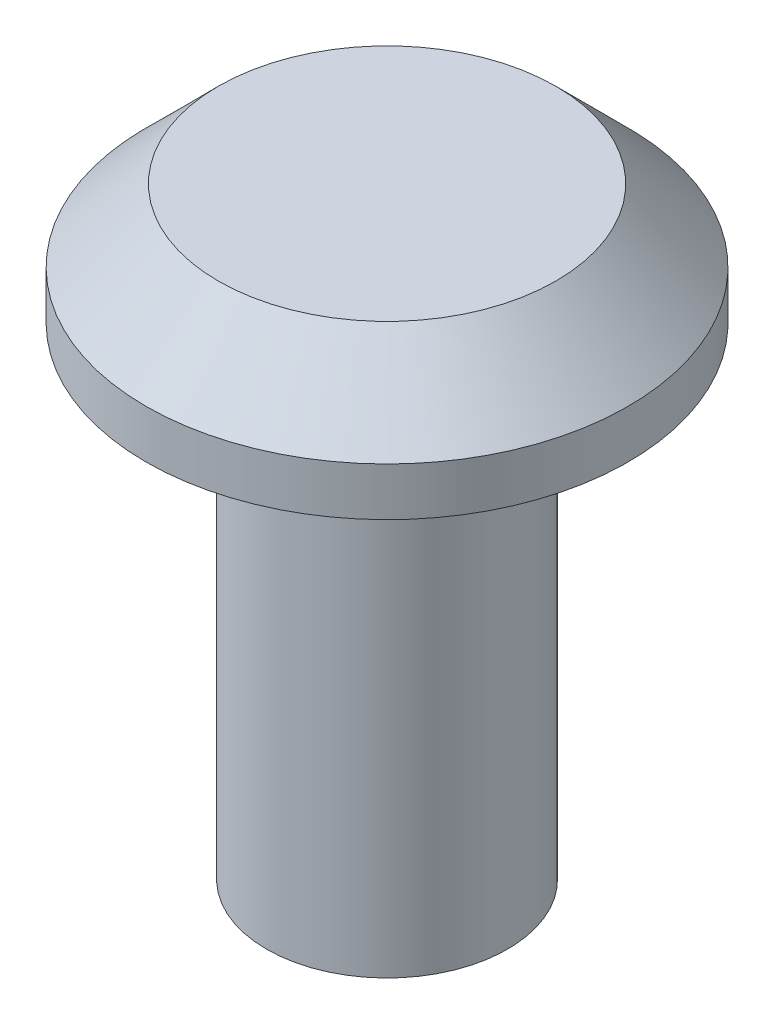
from build123d import *

# Parameters (mm, degrees)
SCHIZZO1_R                   = 1
ESTRUSIONE_ESTRUSIONE1_DEPTH = 0.25
SMUSSO1_SIZE                 = 0.3
SCHIZZO2_R                   = 0.5
ESTRUSIONE_ESTRUSIONE2_DEPTH = 2


with BuildPart() as part:
    # Schizzo1 → Estrusione-Estrusione1 (new body, symmetric)
    with BuildSketch(Plane(origin=(0, 0, 0), x_dir=(1, 0, 0), z_dir=(0, 1, 0))):
        Circle(SCHIZZO1_R)
    extrude(amount=ESTRUSIONE_ESTRUSIONE1_DEPTH, both=True)

    # Smusso1
    smusso1_edges = [part.edges().sort_by_distance(p)[0] for p in [
        (-1, 0.25, 0),
    ]]
    chamfer(smusso1_edges, length=SMUSSO1_SIZE)


with BuildPart() as body_2:
    # Schizzo2 → Estrusione-Estrusione2 (new body)
    with BuildSketch(Plane.XZ.offset(0.25)):
        Circle(SCHIZZO2_R)
    extrude(amount=ESTRUSIONE_ESTRUSIONE2_DEPTH)


solid = Compound([part.part, body_2.part])
